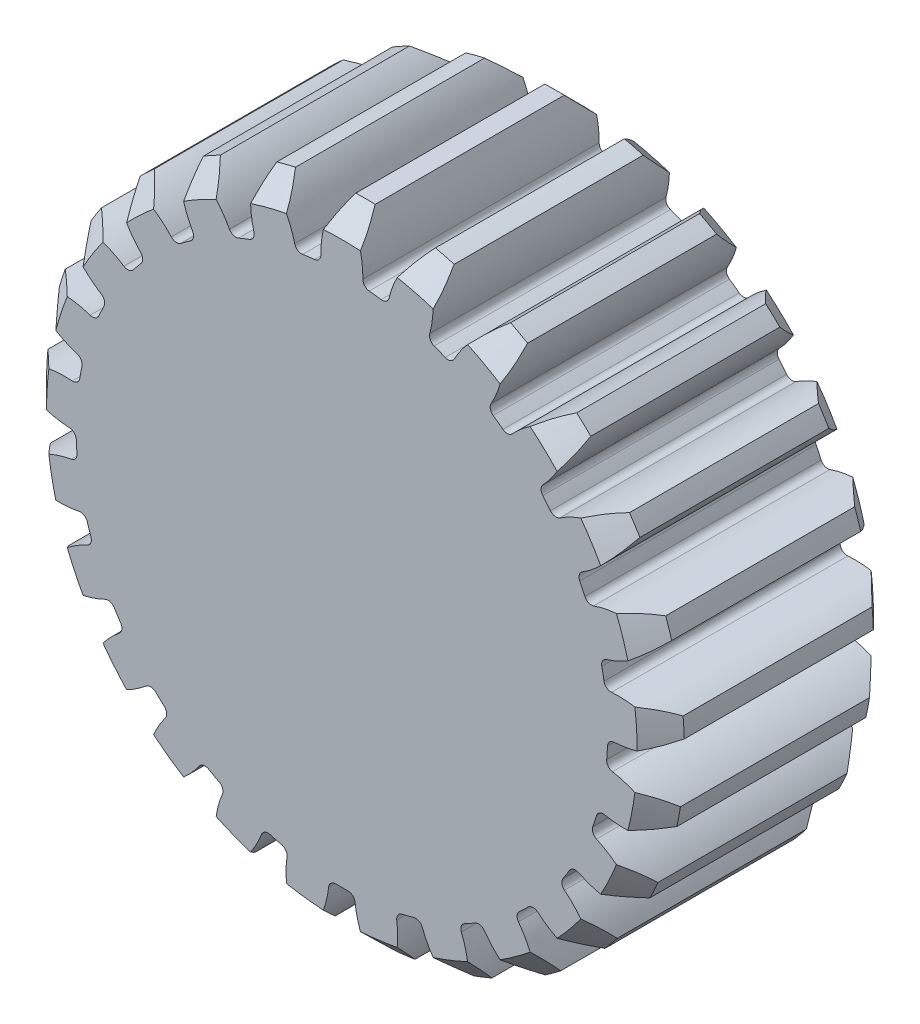
from build123d import *

# Parameters (mm, degrees)
SKETCH2_R                = 27
BOSS_EXTRUDE1_DEPTH      = 10
CUT_EXTRUDE1_DEPTH       = 11
FILLET1_R                = 0.6
CHAMFER1_SIZE            = 2
CIRPATTERN1_COUNT        = 25
FILLET1_OF_CIRPATTERN1_R = 0.6


with BuildPart() as part:
    # Sketch2 → Boss-Extrude1 (new body, symmetric)
    with BuildSketch(Plane.XY):
        Circle(SKETCH2_R)
    extrude(amount=BOSS_EXTRUDE1_DEPTH, both=True)

    # Sketch3 → Cut-Extrude1 (cut, symmetric)
    with BuildSketch(Plane(origin=(0, 0, 0), x_dir=(1, 0, 0), z_dir=(0, 0, -1))):
        with BuildLine():
            ThreePointArc((1.072022538, 22.474446994), (0, 22.5), (-1.072022538, 22.474446994))
            ThreePointArc((-1.072022538, 22.474446994), (-1.510220721, 24.781486697), (-2.569085244, 26.877496182))
            ThreePointArc((-2.569085244, 26.877496182), (0, 27), (2.569085244, 26.877496182))
            ThreePointArc((2.569085244, 26.877496182), (1.510220721, 24.781486697), (1.072022538, 22.474446994))
        make_face()
    cut_extrude1 = extrude(amount=CUT_EXTRUDE1_DEPTH, both=True, mode=Mode.SUBTRACT)

    # Fillet1
    fillet1_edges = [part.edges().sort_by_distance(p)[0] for p in [
        (1.072022538, -22.474446994, 0),
        (-1.072022538, -22.474446994, 0),
    ]]
    fillet(fillet1_edges, radius=FILLET1_R)

    # Chamfer1
    chamfer1_edges = [part.edges().sort_by_distance(p)[0] for p in [
        (0, 27, -10),
        (0, 27, 10),
    ]]
    chamfer(chamfer1_edges, length=CHAMFER1_SIZE)

    # CirPattern1: Cut-Extrude1 ×25 about axis
    cirpattern1_axis = Axis((0, 0, 0), (0, 0, 1))
    for i in range(1, CIRPATTERN1_COUNT):
        add(cut_extrude1.rotate(cirpattern1_axis, i * 360 / CIRPATTERN1_COUNT), mode=Mode.SUBTRACT)

    # Fillet1 of CirPattern1
    fillet1_of_cirpattern1_edges = [part.edges().sort_by_distance(p)[0] for p in [
        (6.627510666, -21.50176975, 0),
        (4.550824708, -22.034972078, 0),
        (11.766567924, -19.178057235, 0),
        (9.887726902, -20.210958827, 0),
        (16.166288445, -15.649316851, 0),
        (14.603346849, -17.117016703, 0),
        (19.550221608, -11.137272336, 0),
        (18.401384806, -12.947549467, 0),
        (21.705742446, -5.92543204, 0),
        (21.043196081, -7.964540081, 0),
        (22.497411659, -0.341275057, 0),
        (22.362785954, -2.481089349, 0),
        (21.875485757, 5.264325494, 0),
        (22.277239742, 3.158257351, 0),
        (19.879042632, 10.539149113, 0),
        (20.791932626, 8.599159126, 0),
        (16.63352615, 15.151759232, 0),
        (18.000191916, 13.499744108, 0),
        (12.342864045, 18.812328595, 0),
        (14.077432948, 17.552090519, 0),
        (7.276654398, 21.290850165, 0),
        (9.270137095, 20.501574531, 0),
        (1.753225794, 22.431589318, 0),
        (3.880364434, 22.162869215, 0),
        (-3.880364434, 22.162869215, 0),
        (-1.753225794, 22.431589318, 0),
        (-9.270137095, 20.501574531, 0),
        (-7.276654398, 21.290850165, 0),
        (-14.077432948, 17.552090519, 0),
        (-12.342864045, 18.812328595, 0),
        (-18.000191916, 13.499744108, 0),
        (-16.63352615, 15.151759232, 0),
        (-20.791932626, 8.599159126, 0),
        (-19.879042632, 10.539149113, 0),
        (-22.277239742, 3.158257351, 0),
        (-21.875485757, 5.264325494, 0),
        (-22.362785954, -2.481089349, 0),
        (-22.497411659, -0.341275057, 0),
        (-21.043196081, -7.964540081, 0),
        (-21.705742446, -5.92543204, 0),
        (-18.401384806, -12.947549467, 0),
        (-19.550221608, -11.137272336, 0),
        (-14.603346849, -17.117016703, 0),
        (-16.166288445, -15.649316851, 0),
        (-9.887726902, -20.210958827, 0),
        (-11.766567924, -19.178057235, 0),
        (-4.550824708, -22.034972078, 0),
        (-6.627510666, -21.50176975, 0),
    ]]
    fillet(fillet1_of_cirpattern1_edges, radius=FILLET1_OF_CIRPATTERN1_R)


solid = part.part
